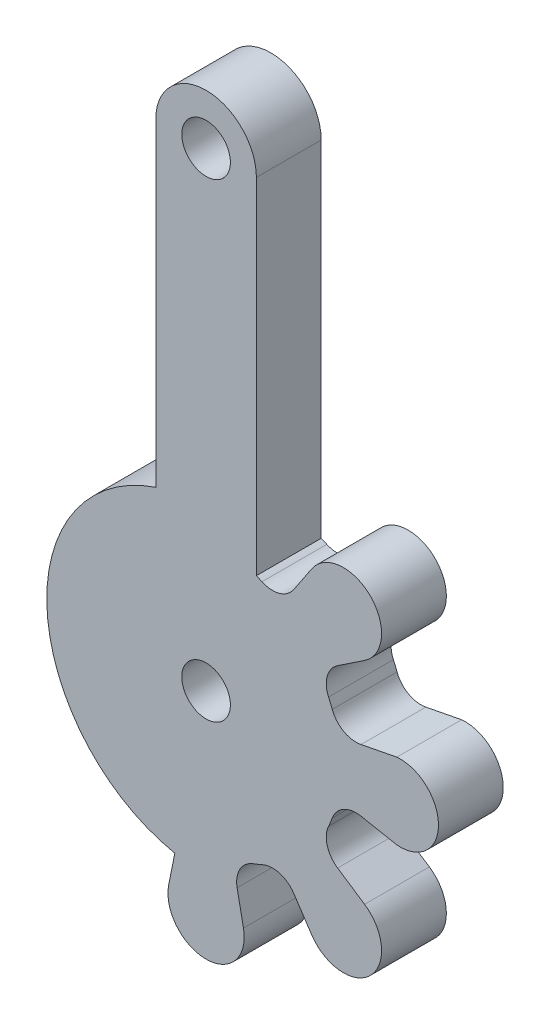
from build123d import *

# Parameters (mm, degrees)
SKETCH1_R           = 1.5
BOSS_EXTRUDE1_DEPTH = 4


with BuildPart() as part:
    # Sketch1 → Boss-Extrude1 (new body)
    with BuildSketch(Plane.XY):
        with BuildLine():
            Line((15.238123377, 6.19825268), (16.347575878, 4.533215952))
            ThreePointArc((16.347575878, 4.533215952), (16.410300459, 4.443659946), (16.477115989, 4.357113217))
            ThreePointArc((16.477115989, 4.357113217), (16.486629929, 4.345440812), (16.496218344, 4.333829508))
            ThreePointArc((16.496218344, 4.333829508), (19.970988274, 4.173992248), (19.811151014, 7.648762179))
            ThreePointArc((19.811151014, 7.648762179), (19.79953971, 7.658350594), (19.787867306, 7.667864534))
            ThreePointArc((19.787867306, 7.667864534), (19.701320577, 7.734680065), (19.61176457, 7.797404645))
            Line((19.61176457, 7.797404645), (17.946727843, 8.906857145))
            ThreePointArc((17.946727843, 8.906857145), (17.307596881, 9.783053451), (17.389325425, 10.864501))
            ThreePointArc((17.389325425, 10.864501), (17.507217214, 11.135394708), (17.61540591, 11.410307569))
            ThreePointArc((17.61540591, 11.410307569), (18.322313997, 12.232797271), (19.393812184, 12.400427786))
            Line((19.393812184, 12.400427786), (21.601765932, 11.971688999))
            ThreePointArc((21.601765932, 11.971688999), (24.171821324, 14.31570037), (21.601765932, 16.65971174))
            Line((21.601765932, 16.65971174), (19.393812182, 16.230972956))
            ThreePointArc((19.393812182, 16.230972956), (18.322313995, 16.398603469), (17.615405908, 17.221093173))
            ThreePointArc((17.615405908, 17.221093173), (17.507217213, 17.496006033), (17.389325429, 17.766899742))
            ThreePointArc((17.389325429, 17.766899742), (17.307596884, 18.848347289), (17.946727842, 19.724543597))
            Line((17.946727842, 19.724543597), (19.61176457, 20.833996096))
            ThreePointArc((19.61176457, 20.833996096), (19.701320577, 20.896720677), (19.787867306, 20.963536208))
            ThreePointArc((19.787867306, 20.963536208), (19.79953971, 20.973050148), (19.811151014, 20.982638563))
            ThreePointArc((19.811151014, 20.982638563), (19.970988274, 24.457408494), (16.496218344, 24.297571234))
            ThreePointArc((16.496218344, 24.297571234), (16.486629929, 24.28595993), (16.477115989, 24.274287526))
            ThreePointArc((16.477115989, 24.274287526), (16.410300458, 24.187740797), (16.347575878, 24.09818479))
            Line((16.347575878, 24.09818479), (15.238123378, 22.433148063))
            ThreePointArc((15.238123378, 22.433148063), (14.36192707, 21.794017099), (13.280479519, 21.875745645))
            ThreePointArc((13.280479519, 21.875745645), (13.108222359, 21.952034546), (12.93428015, 22.024399135))
            Line((12.93428015, 22.024399135), (12.93428015, 43.31570037))
            ThreePointArc((12.93428015, 43.31570037), (9.82928015, 46.42070037), (6.72428015, 43.31570037))
            Line((6.72428015, 43.31570037), (6.72428015, 23.645064295))
            ThreePointArc((6.72428015, 23.645064295), (0.015567267, 13.708167902), (7.898674921, 4.674599826))
            Line((7.898674921, 4.674599826), (7.521150189, 2.789308191))
            ThreePointArc((7.521150189, 2.789308191), (7.502177507, 2.681629554), (7.488225443, 2.57318606))
            ThreePointArc((7.488225443, 2.57318606), (7.486699178, 2.558205052), (7.485268779, 2.543214587))
            ThreePointArc((7.485268779, 2.543214587), (9.82928015, -0.026840804), (12.173291521, 2.543214587))
            ThreePointArc((12.173291521, 2.543214587), (12.171861122, 2.558205052), (12.170334857, 2.57318606))
            ThreePointArc((12.170334857, 2.57318606), (12.156382793, 2.681629555), (12.137410113, 2.789308193))
            Line((12.137410113, 2.789308193), (11.744552736, 4.751168341))
            ThreePointArc((11.744552736, 4.751168341), (11.912183252, 5.822666526), (12.734672953, 6.529574612))
            ThreePointArc((12.734672953, 6.529574612), (13.009585814, 6.637763307), (13.280479523, 6.755655094))
            ThreePointArc((13.280479523, 6.755655094), (14.361927069, 6.837383639), (15.238123377, 6.19825268))
        make_face()
        with Locations((9.82928015, 14.31570037)):
            Circle(SKETCH1_R, mode=Mode.SUBTRACT)
        with Locations((9.82928015, 43.31570037)):
            Circle(SKETCH1_R, mode=Mode.SUBTRACT)
    extrude(amount=BOSS_EXTRUDE1_DEPTH)


solid = part.part
